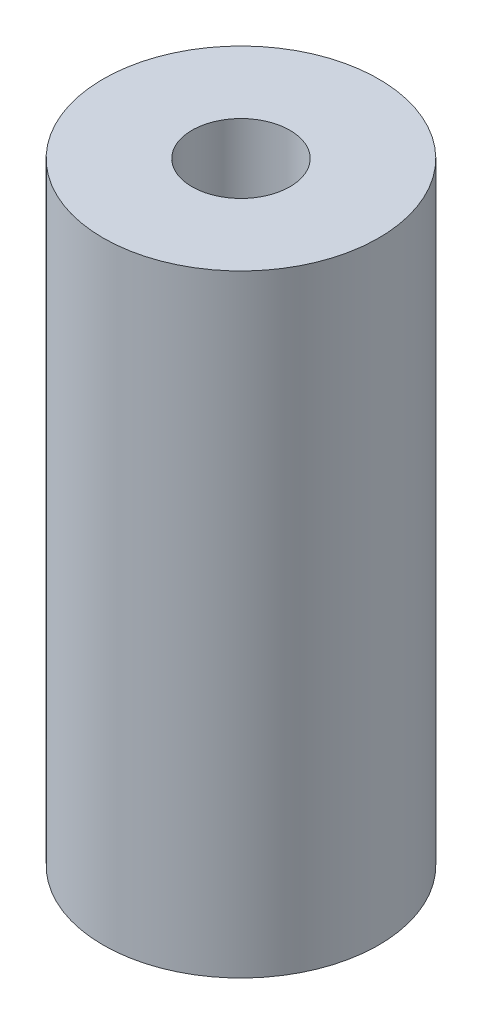
from build123d import *

# Parameters (mm, degrees)
SKETCH1_R             = 2.25
BOSS_EXTRUDE1_DEPTH   = 10
M2X0_4_TAPPED_HOLE1_D = 1.6


with BuildPart() as part:
    # Sketch1 → Boss-Extrude1 (new body)
    with BuildSketch(Plane(origin=(0, 0, 0), x_dir=(1, 0, 0), z_dir=(0, 1, 0))):
        Circle(SKETCH1_R)
    extrude(amount=BOSS_EXTRUDE1_DEPTH)

    # M2x0.4 Tapped Hole1 (through all)
    with Locations(Plane(origin=(0, 10, 0), x_dir=(1, 0, 0), z_dir=(0, 1, 0))):
        with Locations((0, 0)):
            Hole(M2X0_4_TAPPED_HOLE1_D / 2)


solid = part.part
